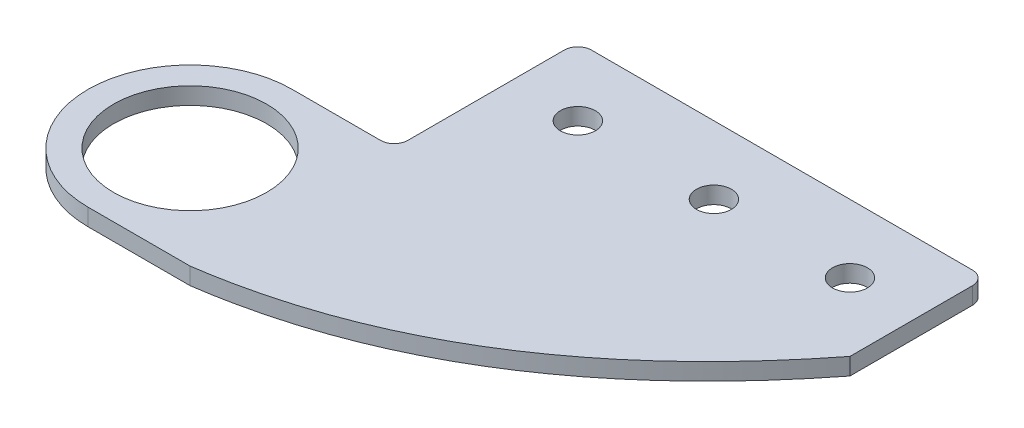
from build123d import *

# Parameters (mm, degrees)
SKETCH1_R           = 14.2875
SKETCH1_R_2         = 3.2639
BOSS_EXTRUDE1_DEPTH = 3.175
FILLET1_R           = 2.54


with BuildPart() as part:
    # Sketch1 → Boss-Extrude1 (new body)
    with BuildSketch(Plane(origin=(0, 0, 0), x_dir=(1, 0, 0), z_dir=(0, 1, 0))):
        with BuildLine():
            Line((-38.1, -28.693802537), (-57.15, -28.693802537))
            ThreePointArc((-57.15, -28.693802537), (-76.2, -47.743802537), (-57.15, -66.793802537))
            Line((-57.15, -66.793802537), (-38.1, -66.793802537))
            add(Edge.make_bspline(
                [(38.1, -19.803802537), (6.35, -60.443802537), (-38.1, -66.793802537)],
                knots=[0, 0, 0, 1, 1, 1], degree=2))
            Line((38.1, -19.803802537), (38.1, 5.596197463))
            Line((38.1, 5.596197463), (-38.1, 5.596197463))
            Line((-38.1, 5.596197463), (-38.1, -28.693802537))
        make_face()
        with Locations((-57.15, -47.743802537)):
            Circle(SKETCH1_R, mode=Mode.SUBTRACT)
        with Locations((-25.4, -7.103802537)):
            Circle(SKETCH1_R_2, mode=Mode.SUBTRACT)
        with Locations((0, -7.103802537)):
            Circle(SKETCH1_R_2, mode=Mode.SUBTRACT)
        with Locations((25.4, -7.103802537)):
            Circle(SKETCH1_R_2, mode=Mode.SUBTRACT)
    extrude(amount=BOSS_EXTRUDE1_DEPTH)

    # Fillet1
    fillet1_edges = [part.edges().sort_by_distance(p)[0] for p in [
        (-38.1, 1.5875, 28.693802537),
        (-38.1, 1.5875, -5.596197463),
        (38.1, 1.5875, -5.596197463),
    ]]
    fillet(fillet1_edges, radius=FILLET1_R)


solid = part.part
